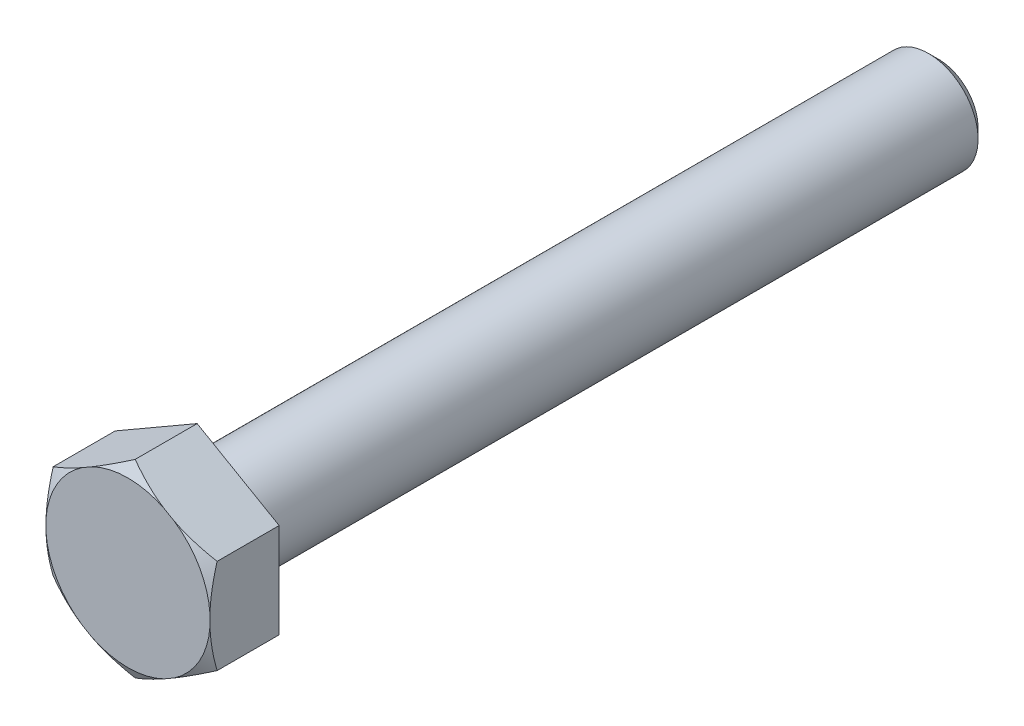
from build123d import *

# Parameters (mm, degrees)
SKETCH_2_OUTSIDE_W  = 16.94
SKETCH_2_OUTSIDE_H  = 16.94
CUT_EXTRUDE_1_DEPTH = 2.8
CHAMFER_1_SIZE      = 0.4
FILLET_1_R          = 0.4


with BuildPart() as part:
    # Эскиз1 → Повернуть1 (revolve)
    with BuildSketch(Plane(origin=(0, 0, 0), x_dir=(1, 0, 0), z_dir=(0, 1, 0))):
        Polygon((0, 0), (-4, 0), (-4, 2.8), (-2, 2.8), (-2, 32.8), (0, 32.8), align=None)
    revolve(axis=Axis((0, 0, -32.8), (0, 0, 1)))

    # Эскиз2 outside → Вырез-Вытянуть1 (cut)
    with BuildSketch(Plane.XY):
        Rectangle(SKETCH_2_OUTSIDE_W, SKETCH_2_OUTSIDE_H)
        Polygon((0, 3.83), (-3.316877296, 1.915), (-3.316877296, -1.915), (0, -3.83), (3.316877296, -1.915), (3.316877296, 1.915), align=None, mode=Mode.SUBTRACT)
    extrude(amount=-CUT_EXTRUDE_1_DEPTH, mode=Mode.SUBTRACT)

    # Эскиз3 → Вырез-Повернуть1 (revolve, cut)
    with BuildSketch(Plane(origin=(0, 0, 0), x_dir=(0, 0, -1), z_dir=(1, 0, 0))):
        Polygon((0, 3.83), (0.291561886, 3.83), (0, 3.325), align=None)
    revolve(axis=Axis((0, 0, 0), (0, 0, 1)), mode=Mode.SUBTRACT)

    # Фаска1
    chamfer_1_edges = [part.edges().sort_by_distance(p)[0] for p in [
        (2, 0, -32.8),
    ]]
    chamfer(chamfer_1_edges, length=CHAMFER_1_SIZE)

    # Скругление1
    fillet_1_edges = [part.edges().sort_by_distance(p)[0] for p in [
        (2, 0, -2.8),
    ]]
    fillet(fillet_1_edges, radius=FILLET_1_R)


solid = part.part
